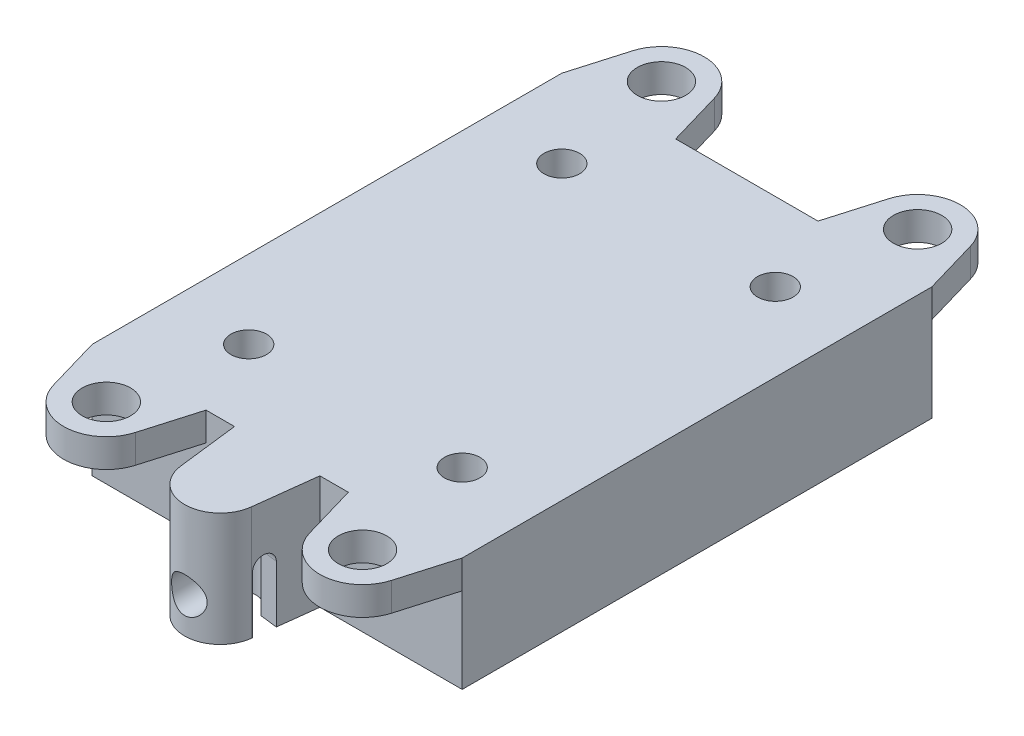
from build123d import *

# Parameters (mm, degrees)
BOSS_EXTRUDE1_DEPTH              = 8
BOSS_EXTRUDE2_DEPTH              = 2
SKETCH3_W                        = 22
SKETCH3_H                        = 29
CUT_EXTRUDE1_DEPTH               = 3
SKETCH4_R                        = 1.5
CUT_EXTRUDE2_DEPTH               = 5
TAP_DRILL_FOR_M3X0_5_TAP1_REACH  = 49.639
TAP_DRILL_FOR_M3X0_5_TAP1_BORE_R = 1.25
M3_CLEARANCE_HOLE1_D             = 3.4
TAP_DRILL_FOR_M3X0_5_TAP2_D      = 2.5
SKETCH10_W                       = 4
SKETCH10_H                       = 13
CUT_EXTRUDE3_DEPTH               = 2
CUT_EXTRUDE4_REACH               = 45.215


with BuildPart() as part:
    # Sketch1 → Boss-Extrude1 (new body)
    with BuildSketch(Plane(origin=(0, 0, 0), x_dir=(1, 0, 0), z_dir=(0, 1, 0))):
        with BuildLine():
            Line((-2.482050808, -4.299038106), (-3, 0))
            Line((-3, 0), (-13, 0))
            Line((-13, 0), (-13, 33))
            Line((-13, 33), (13, 33))
            Line((13, 33), (13, 0))
            Line((13, 0), (3, 0))
            Line((3, 0), (2.482050808, -4.299038106))
            ThreePointArc((2.482050808, -4.299038106), (0, -6.5), (-2.482050808, -4.299038106))
        make_face()
    extrude(amount=BOSS_EXTRUDE1_DEPTH)

    # Sketch2 → Boss-Extrude2 (add)
    with BuildSketch(Plane(origin=(0, 8, 0), x_dir=(1, 0, 0), z_dir=(0, 1, 0))):
        with BuildLine():
            Line((-11.88, 36.84), (-13, 33))
            Line((-13, 33), (-5, 33))
            Line((-5, 33), (-6.12, 36.84))
            ThreePointArc((-6.12, 36.84), (-9, 39), (-11.88, 36.84))
        make_face()
        with BuildLine():
            Line((5, 33), (13, 33))
            Line((13, 33), (11.88, 36.84))
            ThreePointArc((11.88, 36.84), (9, 39), (6.12, 36.84))
            Line((6.12, 36.84), (5, 33))
        make_face()
        with BuildLine():
            Line((-5, 0), (-13, 0))
            Line((-13, 0), (-11.88, -3.84))
            ThreePointArc((-11.88, -3.84), (-9, -6), (-6.12, -3.84))
            Line((-6.12, -3.84), (-5, 0))
        make_face()
        with BuildLine():
            Line((11.88, -3.84), (13, 0))
            Line((13, 0), (5, 0))
            Line((5, 0), (6.12, -3.84))
            ThreePointArc((6.12, -3.84), (9, -6), (11.88, -3.84))
        make_face()
    extrude(amount=-BOSS_EXTRUDE2_DEPTH)

    # Sketch3 → Cut-Extrude1 (cut)
    with BuildSketch(Plane.XZ):
        with Locations((0, -16.5)):
            Rectangle(SKETCH3_W, SKETCH3_H)
    extrude(amount=-CUT_EXTRUDE1_DEPTH, mode=Mode.SUBTRACT)

    # Sketch4 → Cut-Extrude2 (cut)
    with BuildSketch(Plane(origin=(0, 0, 0), x_dir=(-1, 0, 0), z_dir=(0, -1, 0))):
        with Locations(Location((0, -3, 0), (0, 0, 90))):
            Circle(SKETCH4_R)
    extrude(amount=-CUT_EXTRUDE2_DEPTH, mode=Mode.SUBTRACT)

    # Tap Drill for M3x0.5 Tap1 bore (on position points) → Tap Drill for M3x0.5 Tap1 (cut, up to next)
    with BuildSketch(Plane(origin=(0, 2.5, 6.5), x_dir=(1, 0, 0), z_dir=(0, 0, 1)), mode=Mode.PRIVATE) as tap_drill_for_m3x0_5_tap1_sk1:
        Circle(TAP_DRILL_FOR_M3X0_5_TAP1_BORE_R)
    tap_drill_for_m3x0_5_tap1_tool1 = extrude(tap_drill_for_m3x0_5_tap1_sk1.sketch, amount=-TAP_DRILL_FOR_M3X0_5_TAP1_REACH, mode=Mode.PRIVATE) & part.part
    add(tap_drill_for_m3x0_5_tap1_tool1.solids().sort_by_distance((0, 2.5, 6.5))[0], mode=Mode.SUBTRACT)

    # M3 Clearance Hole1 (through all)
    with Locations(Plane(origin=(0, 6, 0), x_dir=(-1, 0, 0), z_dir=(0, -1, 0))):
        with Locations((9, -3), (-9, -3), (9, 36), (-9, 36)):
            Hole(M3_CLEARANCE_HOLE1_D / 2)

    # Tap Drill for M3x0.5 Tap2 (through all)
    with Locations(Plane(origin=(0, 3, 0), x_dir=(-1, 0, 0), z_dir=(0, -1, 0))):
        with Locations((7.5, 5.5), (7.5, 27.5), (-7.5, 27.5), (-7.5, 5.5)):
            Hole(TAP_DRILL_FOR_M3X0_5_TAP2_D / 2)

    # Sketch10 → Cut-Extrude3 (cut)
    with BuildSketch(Plane(origin=(0, 3, 0), x_dir=(-1, 0, 0), z_dir=(0, -1, 0))):
        with Locations((-7, 16.5)):
            Rectangle(SKETCH10_W, SKETCH10_H)
    extrude(amount=-CUT_EXTRUDE3_DEPTH, mode=Mode.SUBTRACT)

    # Sketch19 → Cut-Extrude4 (cut, up to next)
    with BuildSketch(Plane(origin=(2.957076581, 0, 0.35626933), x_dir=(0.11961524227066314, 0, -0.992820323027551), z_dir=(0.9928203230275511, 0, 0.11961524227066316)), mode=Mode.PRIVATE) as cut_extrude4_sk1:
        with BuildLine():
            Line((-2.391154273, 0), (-2.391154273, 4))
            ThreePointArc((-2.391154273, 4), (-3.141154273, 4.75), (-3.891154273, 4))
            Line((-3.891154273, 4), (-3.891154273, 0))
            Line((-3.891154273, 0), (-2.391154273, 0))
        make_face()
    cut_extrude4_tool1 = extrude(cut_extrude4_sk1.sketch, amount=-CUT_EXTRUDE4_REACH, mode=Mode.PRIVATE) & part.part
    add(cut_extrude4_tool1.solids().sort_by_distance((2.581347, 2.297577, 3.474871))[0], mode=Mode.SUBTRACT)


solid = part.part
